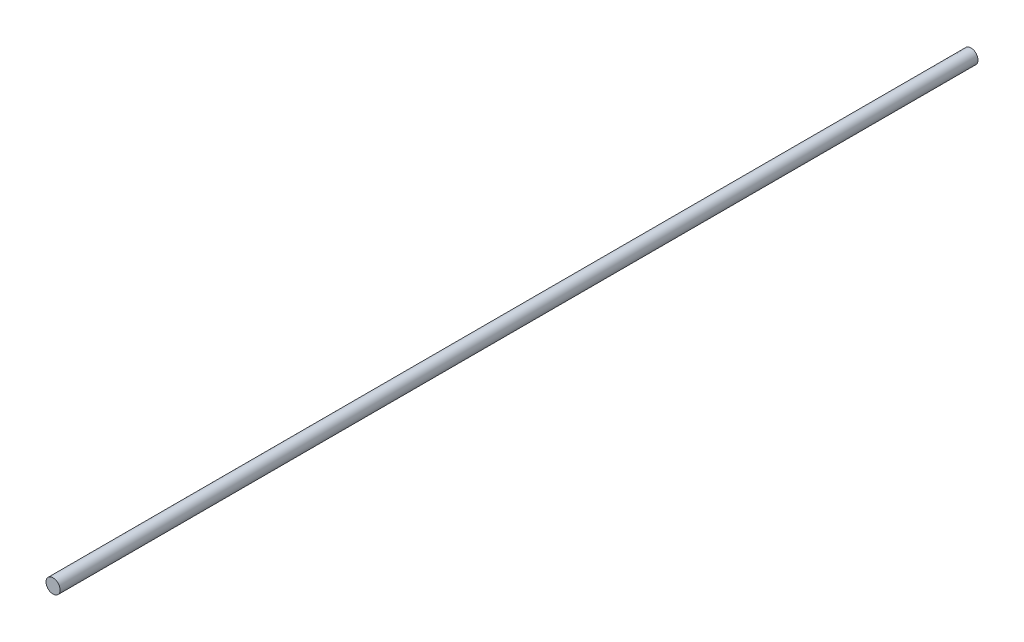
from build123d import *

# Parameters (mm, degrees)
SKETCH1_R           = 4
BOSS_EXTRUDE1_DEPTH = 520


with BuildPart() as part:
    # Sketch1 → Boss-Extrude1 (new body)
    with BuildSketch(Plane.XY):
        Circle(SKETCH1_R)
    extrude(amount=BOSS_EXTRUDE1_DEPTH)


solid = part.part
